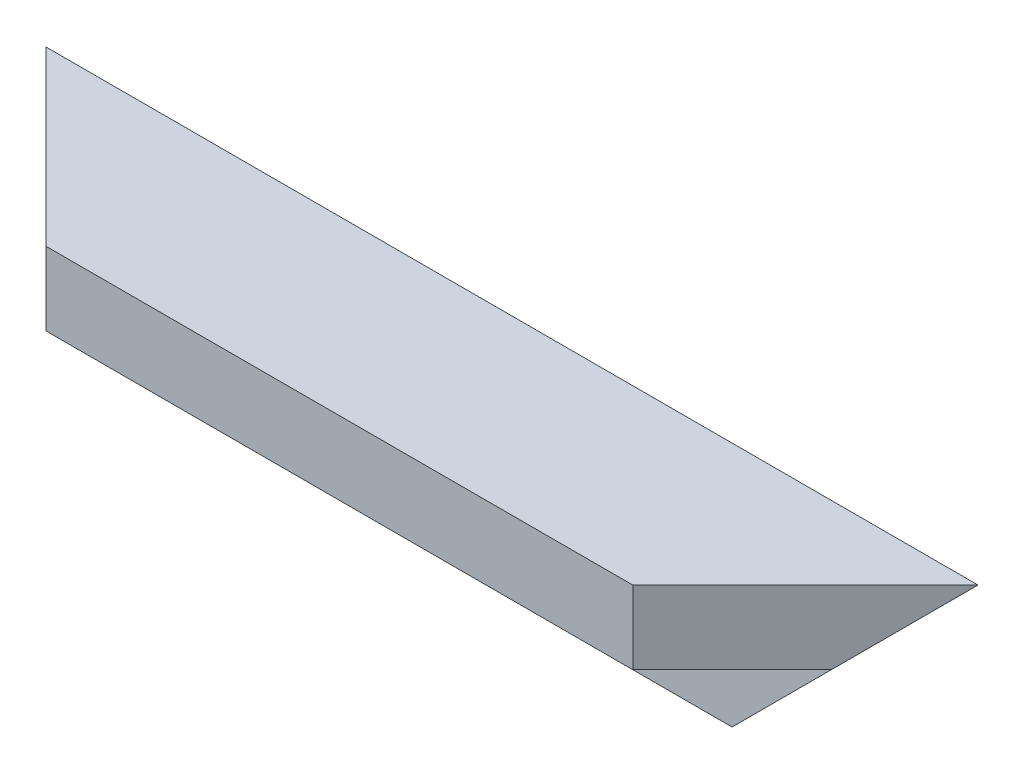
from build123d import *

# Parameters (mm, degrees)
BOSS_EXTRU_1_DEPTH      = 216
ENL_V_MAT_EXTRU_1_DEPTH = 41
ENL_V_MAT_EXTRU_2_DEPTH = 41


with BuildPart() as part:
    # Esquisse1 → Boss.-Extru.1 (new body)
    with BuildSketch(Plane(origin=(0, 0, 0), x_dir=(0, 0, -1), z_dir=(1, 0, 0))):
        Polygon((0, 0), (-40, 0), (-40, -17), (-17, -17), (-17, -40), (0, -40), align=None)
    extrude(amount=BOSS_EXTRU_1_DEPTH)

    # Esquisse2 → Enlèv. mat.-Extru.1 (cut, through all)
    with BuildSketch(Plane(origin=(0, 0, 0), x_dir=(1, 0, 0), z_dir=(0, 1, 0))):
        Polygon((216, 0), (176, -40), (216, -40), align=None)
        Polygon((0, 0), (0, -40), (40, -40), align=None)
    extrude(amount=-ENL_V_MAT_EXTRU_1_DEPTH, mode=Mode.SUBTRACT)

    # Esquisse3 → Enlèv. mat.-Extru.2 (cut, through all)
    with BuildSketch(Plane(origin=(0, 0, 0), x_dir=(-1, 0, 0), z_dir=(0, 0, -1))):
        Polygon((-216, 0), (-176, -40), (-216, -40), align=None)
        Polygon((-40, -40), (0, -40), (0, 0), align=None)
    extrude(amount=-ENL_V_MAT_EXTRU_2_DEPTH, mode=Mode.SUBTRACT)


solid = part.part
